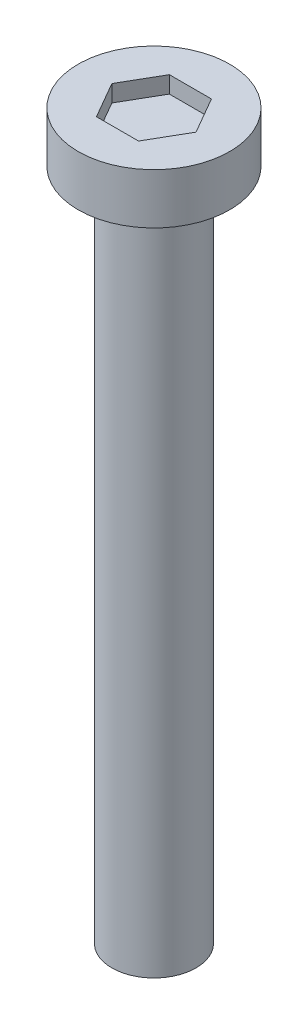
from build123d import *

# Parameters (mm, degrees)
SKETCH1_R           = 1.25
BOSS_EXTRUDE1_DEPTH = 20
SKETCH4_R           = 2.25
BOSS_EXTRUDE2_DEPTH = 1.5
CUT_EXTRUDE1_DEPTH  = 0.5


with BuildPart() as part:
    # Sketch1 → Boss-Extrude1 (new body)
    with BuildSketch(Plane(origin=(0, 0, 0), x_dir=(1, 0, 0), z_dir=(0, 1, 0))):
        Circle(SKETCH1_R)
    extrude(amount=BOSS_EXTRUDE1_DEPTH)

    # Sketch4 → Boss-Extrude2 (add)
    with BuildSketch(Plane(origin=(0, 20, 0), x_dir=(1, 0, 0), z_dir=(0, 1, 0))):
        Circle(SKETCH4_R)
    extrude(amount=BOSS_EXTRUDE2_DEPTH)

    # Sketch5 → Cut-Extrude1 (cut)
    with BuildSketch(Plane(origin=(0, 21.5, 0), x_dir=(1, 0, 0), z_dir=(0, 1, 0))):
        Polygon((1.25, 0), (0.625, 1.082531755), (-0.625, 1.082531755), (-1.25, 0), (-0.625, -1.082531755), (0.625, -1.082531755), align=None)
    extrude(amount=-CUT_EXTRUDE1_DEPTH, mode=Mode.SUBTRACT)


solid = part.part
